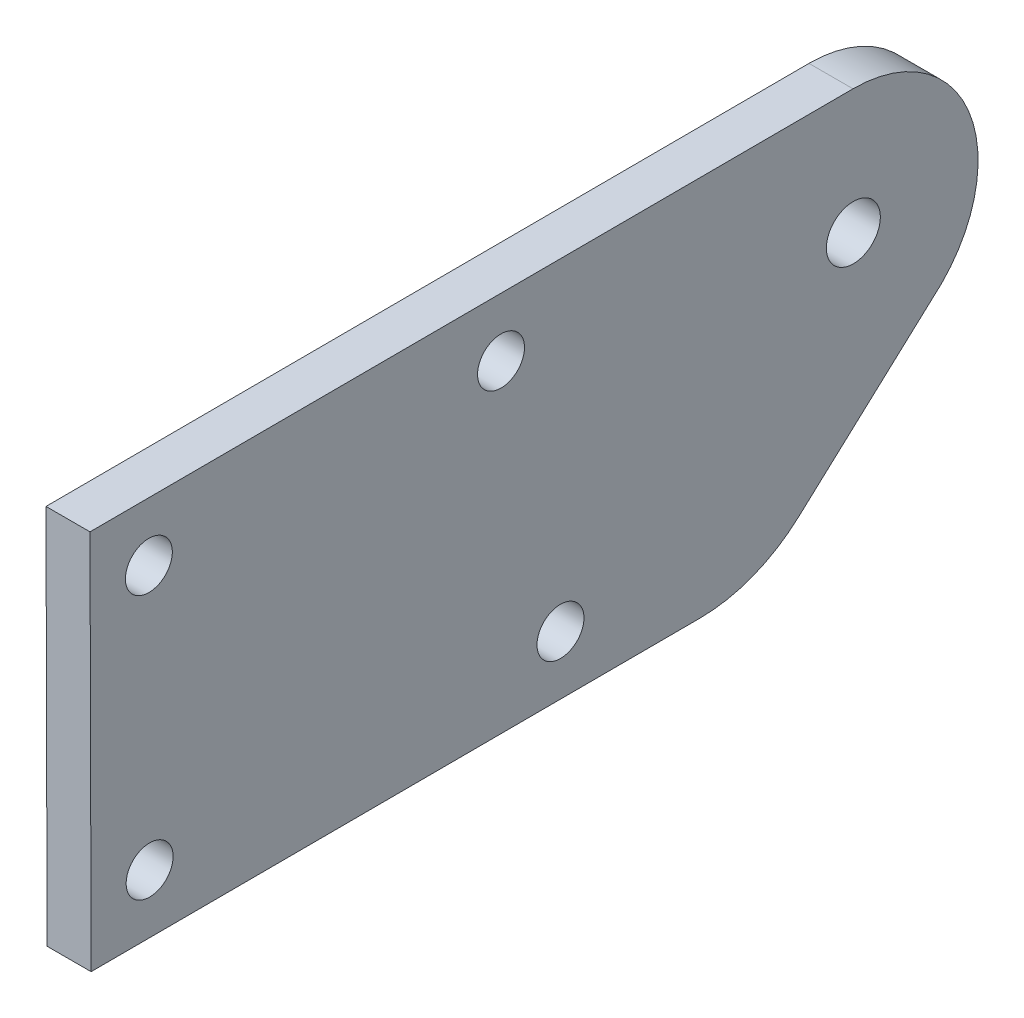
from build123d import *

# Parameters (mm, degrees)
SKETCH_1_R      = 1.839883841
SKETCH_1_R_2    = 1.6
EXTRUDE_1_DEPTH = 3


with BuildPart() as part:
    # 草图1 → 凸台-拉伸1 (new body)
    with BuildSketch(Plane(origin=(0, 0, 0), x_dir=(0, 0, -1), z_dir=(1, 0, 0))):
        with BuildLine():
            Line((-51.910708478, -17.756118332), (-10.410879829, -17.636861799))
            ThreePointArc((-10.410879829, -17.636861799), (-6.80853031, -16.954371319), (-3.69429735, -15.01936011))
            Line((-3.69429735, -15.01936011), (6.053738335, -6.112622142))
            ThreePointArc((6.053738335, -6.112622142), (7.885847556, 3.160295303), (0.014361881, 8.393204188))
            Line((0.014361881, 8.393204188), (-51.985423414, 8.243774315))
            Line((-51.985423414, 8.243774315), (-51.910708478, -17.756118332))
        make_face()
        with Locations((0.038787918, -0.106760716)):
            Circle(SKETCH_1_R, mode=Mode.SUBTRACT)
        with Locations((-47.973945324, 4.255285437)):
            Circle(SKETCH_1_R_2, mode=Mode.SUBTRACT)
        with Locations((-19.92233521, -13.664178003)):
            Circle(SKETCH_1_R_2, mode=Mode.SUBTRACT)
        with Locations((-23.974044419, 4.32425307)):
            Circle(SKETCH_1_R_2, mode=Mode.SUBTRACT)
        with Locations((-47.922219599, -13.744640242)):
            Circle(SKETCH_1_R_2, mode=Mode.SUBTRACT)
    extrude(amount=EXTRUDE_1_DEPTH)


solid = part.part
